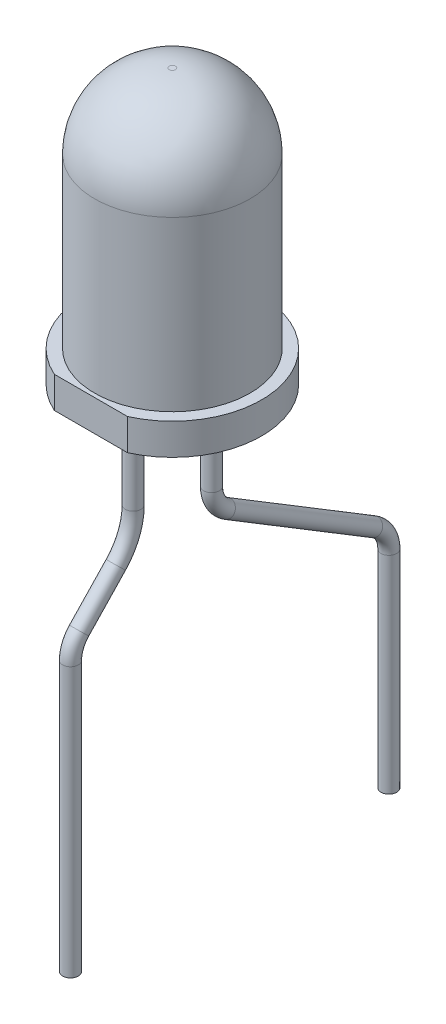
from build123d import *

# Parameters (mm, degrees)
CUT_EXTRUDE1_DEPTH  = 1
SKETCH3_R           = 0.25
BOSS_EXTRUDE1_DEPTH = 2
SKETCH5_R           = 0.25
SKETCH7_R           = 0.25


with BuildPart() as part:
    # Sketch1 → Revolve1 (revolve)
    with BuildSketch(Plane.XY, mode=Mode.PRIVATE) as revolve1_sk:
        with BuildLine():
            Line((0, 0), (0, 8.75))
            Line((0, 8.75), (0.1, 8.75))
            ThreePointArc((0.1, 8.75), (1.782914139, 8.052914139), (2.48, 6.37))
            Line((2.48, 6.37), (2.48, 1))
            Line((2.48, 1), (2.85, 1))
            Line((2.85, 1), (2.85, 0))
            Line((2.85, 0), (0, 0))
        make_face()
    revolve(revolve1_sk.sketch.rotate(Axis((0, 0, 0), (0, 1, 0)), 90), axis=Axis((0, 0, 0), (0, 1, 0)))

    # Sketch2 → Cut-Extrude1 (cut)
    with BuildSketch(Plane.XZ):
        with BuildLine():
            Line((-1.167261753, 2.6), (1.167261753, 2.6))
            ThreePointArc((1.167261753, 2.6), (0, 2.85), (-1.167261753, 2.6))
        make_face()
    extrude(amount=-CUT_EXTRUDE1_DEPTH, mode=Mode.SUBTRACT)

    # Sketch3 → Boss-Extrude1 (add)
    with BuildSketch(Plane.XZ):
        with Locations(Location((0, -1.25, 0), (0, 0, 270))):
            Circle(SKETCH3_R)
        with Locations(Location((0, 1.25, 0), (0, 0, 270))):
            Circle(SKETCH3_R)
    extrude(amount=BOSS_EXTRUDE1_DEPTH)

    # Sweep1: sweep along a path in Sketch4
    with BuildLine(Plane(origin=(0, 0, 0), x_dir=(0, 0, -1), z_dir=(1, 0, 0))) as sweep1_path:
        Line((-1.25, -2), (-1.25, -2.7))
        ThreePointArc((-1.25, -2.7), (-1.393046618, -3.442781353), (-1.801724138, -4.079310345))
        Line((-1.801724138, -4.079310345), (-2.974137931, -5.310344828))
        ThreePointArc((-2.974137931, -5.310344828), (-3.178476691, -5.628609324), (-3.25, -6))
        Line((-3.25, -6), (-3.25, -14.6))
    # Sketch5 → Sweep1 (sweep)
    with BuildSketch(Plane(origin=(0, -14.6, 3.25), x_dir=(-1, 0, 0), z_dir=(0, -1, 0))):
        Circle(SKETCH5_R)
    sweep(path=sweep1_path.line)

    # Sweep2: sweep along a path in Sketch6
    with BuildLine(Plane(origin=(0, 0, 0), x_dir=(0, 0, -1), z_dir=(1, 0, 0))) as sweep2_path:
        Line((6.91, -14.6), (6.91, -8))
        ThreePointArc((6.91, -8), (6.78151551, -7.50963206), (6.429078567, -7.14527347))
        Line((6.429078567, -7.14527347), (1.730921433, -4.292065356))
        ThreePointArc((1.730921433, -4.292065356), (1.37848449, -3.927706766), (1.25, -3.437338826))
        Line((1.25, -3.437338826), (1.25, -2))
    # Sketch7 → Sweep2 (sweep)
    with BuildSketch(Plane(origin=(0, -14.6, -6.91), x_dir=(-1, 0, 0), z_dir=(0, -1, 0))):
        Circle(SKETCH7_R)
    sweep(path=sweep2_path.line)


solid = part.part
